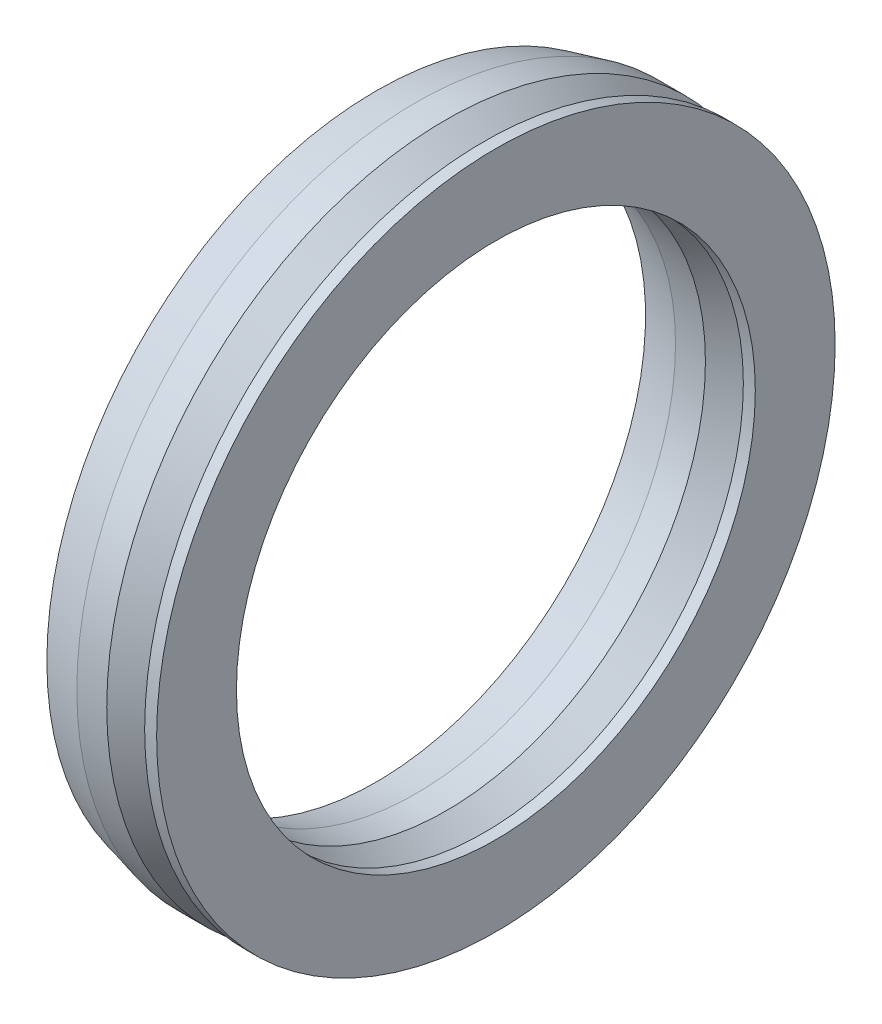
from build123d import *


with BuildPart() as part:
    # Sketch1 → Revolve2 (revolve)
    with BuildSketch(Plane.XY):
        Polygon((0, 34), (0, 26), (-1.2, 26), (-1.2, 28.5), (-2.2, 28.5), (-2.2, 28), (-5, 26), (-8, 26), (-12, 27), (-12, 28), (-8, 27), (-3, 30), (-8, 33), (-12, 32), (-12, 33), (-8, 34), (-5, 34), (-2.2, 32), (-2.2, 31.5), (-1.2, 31.5), (-1.2, 34), align=None)
    revolve(axis=Axis((-63.826580298, 0, 0), (1, 0, 0)))


solid = part.part
